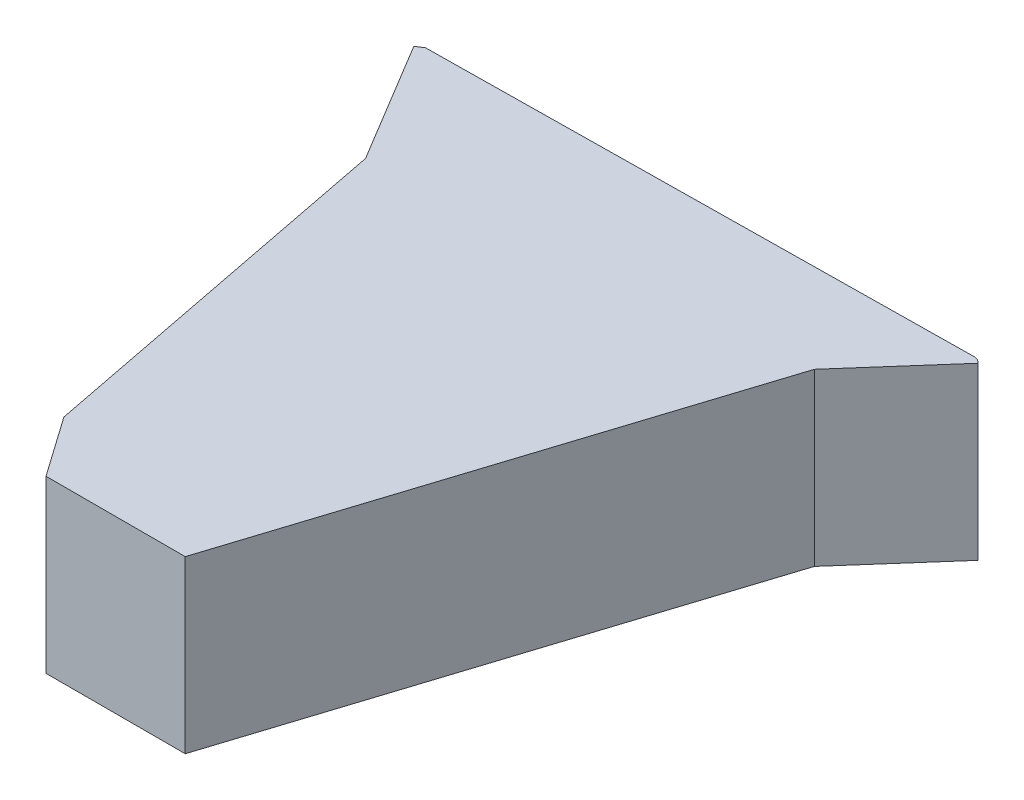
from build123d import *

# Parameters (mm, degrees)
SKETCH_2_R        = 9
EXTRUDE_1_DEPTH   = 80
EXTRUDE_1_2_DEPTH = 80
EXTRUDE_1_3_DEPTH = 80
EXTRUDE_2_DEPTH   = 2


with BuildPart() as part:
    # 草图2 → 凸台-拉伸1 (new body)
    with BuildSketch(Plane(origin=(0, 0, 0), x_dir=(1, 0, 0), z_dir=(0, 1, 0))):
        with Locations((-100.00360092, 94.257346069)):
            Circle(SKETCH_2_R)
    extrude(amount=EXTRUDE_1_DEPTH)



with BuildPart() as body_2:
    # 草图2 → Extrude 1 2 (new body)
    with BuildSketch(Plane(origin=(0, 0, 0), x_dir=(1, 0, 0), z_dir=(0, 1, 0))):
        Polygon((-180.407965552, 313.211742037), (-145.137395052, 254.599587646), (-110.045954215, 74.705720884), (-90.558125094, 46.975459978), (-26.188648694, 46.975459978), (46.650236815, 274.975459978), (83.703115643, 317.123903245), (85.205209719, 315.803405844), (48.428218628, 273.968790786), (-24.728005079, 44.975459978), (-91.597082511, 44.975459978), (-111.927353435, 73.904475802), (-147.032877617, 253.870539869), (-182.121617812, 312.180531131), align=None)
    extrude(amount=EXTRUDE_1_2_DEPTH)


with BuildPart() as body_3:
    # 草图2 → Extrude 1 3 (new body)
    with BuildSketch(Plane(origin=(0, 0, 0), x_dir=(1, 0, 0), z_dir=(0, 1, 0))):
        Polygon((-51.670033073, 193.433505049), (-92.281031996, 169.986733889), (-92.281031996, 123.093191569), (-51.670033073, 99.646420409), (-11.059034151, 123.093191569), (-11.059034151, 169.986733889), align=None)
    extrude(amount=EXTRUDE_1_3_DEPTH)


with BuildPart() as part_1:
    add(part.part)

    add(body_2.part)  # 凸台-拉伸2 merges body 2

    add(body_3.part)  # 凸台-拉伸2 merges body 3
    # 草图3 → 凸台-拉伸2 (add)
    with BuildSketch(Plane(origin=(0, 80, 0), x_dir=(1, 0, 0), z_dir=(0, 1, 0))):
        Polygon((-178.746676914, 314.325348818), (81.764058494, 317.613859747), (83.703115643, 317.123903245), (85.205209719, 315.803405844), (48.428218628, 273.968790786), (-24.728005079, 44.975459978), (-91.597082511, 44.975459978), (-111.927353435, 73.904475802), (-147.032877617, 253.870539869), (-182.121617812, 312.180531131), (-180.407965552, 313.211742037), align=None)
    extrude(amount=EXTRUDE_2_DEPTH)


solid = part_1.part
